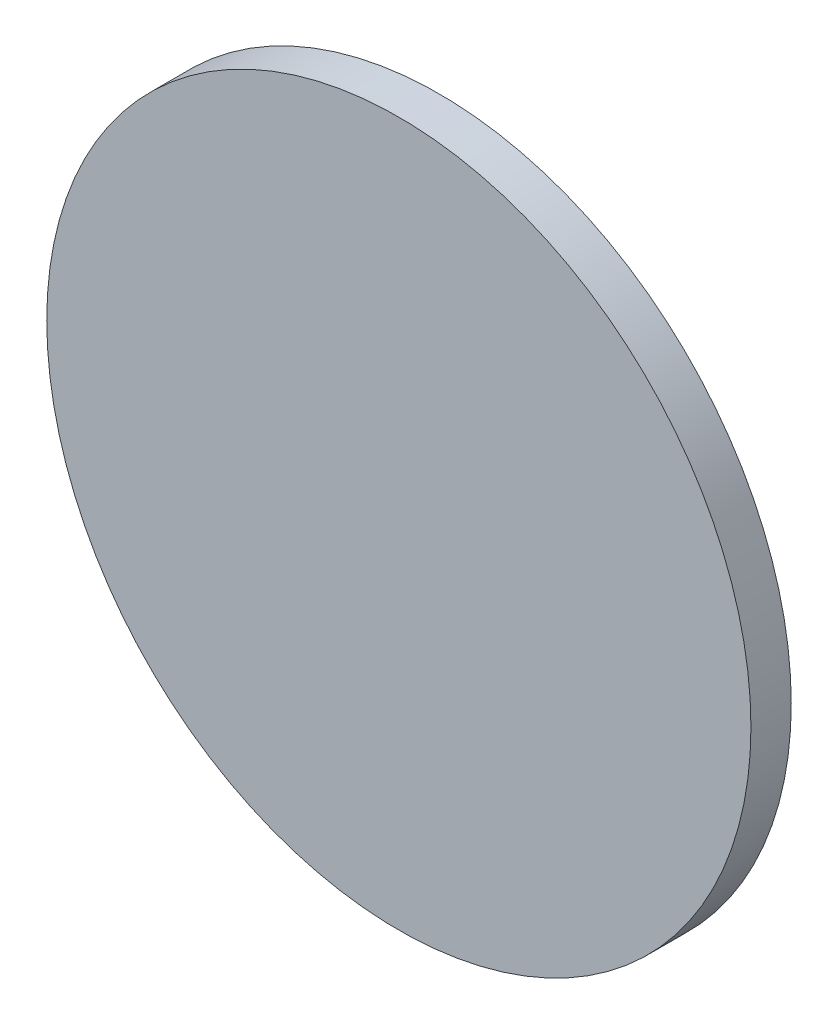
from build123d import *

# Parameters (mm, degrees)
CROQUIS1_R              = 26.2
SALIENTE_EXTRUIR1_DEPTH = 3


with BuildPart() as part:
    # Croquis1 → Saliente-Extruir1 (new body)
    with BuildSketch(Plane.XY):
        Circle(CROQUIS1_R)
    extrude(amount=SALIENTE_EXTRUIR1_DEPTH)


solid = part.part
